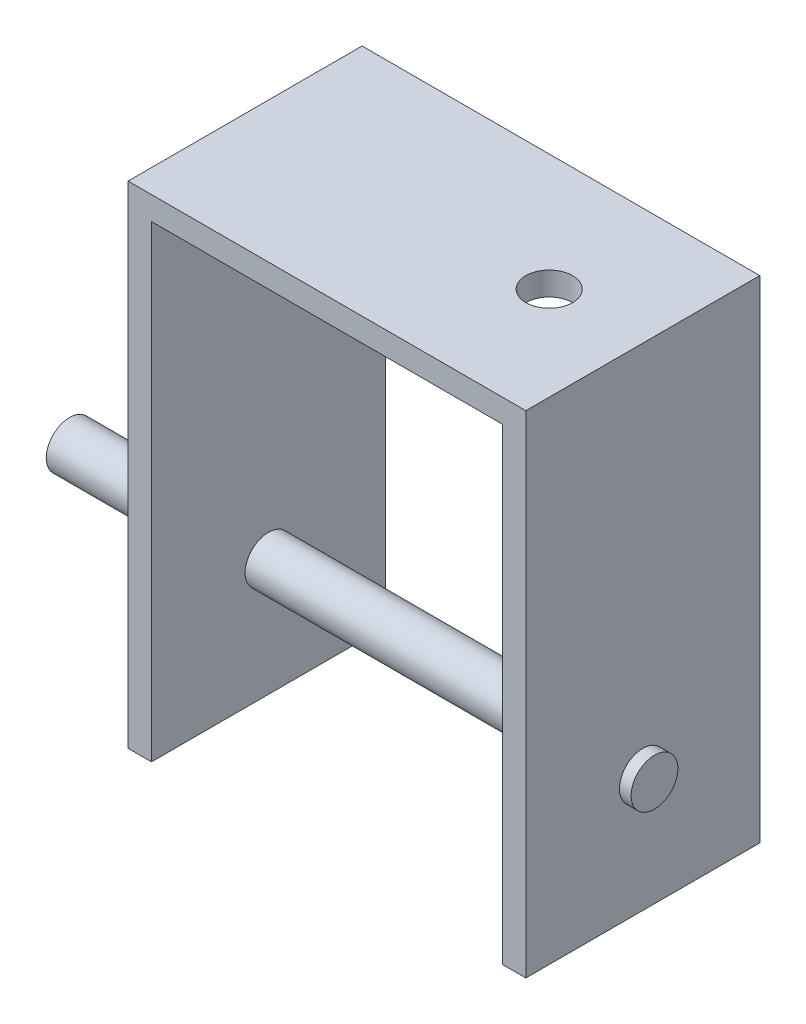
from build123d import *

# Parameters (mm, degrees)
EXTRUDE_1_DEPTH      = 20
SKETCH_3_R           = 2
EXTRUDE_2_DEPTH      = 15
EXTRUDE_2_DEPTH_BACK = 35
SKETCH_4_R           = 2
CUT_EXTRUDE_1_DEPTH  = 2


with BuildPart() as part:
    # 草图1 → 凸台-拉伸1 (new body)
    with BuildSketch(Plane.XY):
        Polygon((-38.9636651, 28.845358616), (-38.9636651, -11.154641384), (-36.9636651, -11.154641384), (-36.9636651, 28.845358616), (-6.9636651, 28.845358616), (-6.9636651, -11.154641384), (-4.9636651, -11.154641384), (-4.9636651, 30.845358616), (-38.9636651, 30.845358616), align=None)
    extrude(amount=EXTRUDE_1_DEPTH)

    # 草图3 → 凸台-拉伸2 (add, two sides)
    with BuildSketch(Plane.ZY.offset(38.9636651)) as extrude_2_sk:
        with Locations((10, -1.154641384)):
            Circle(SKETCH_3_R)
    extrude(amount=EXTRUDE_2_DEPTH)
    extrude(extrude_2_sk.sketch, amount=-EXTRUDE_2_DEPTH_BACK)

    # 草图4 → 切除-拉伸1 (cut)
    with BuildSketch(Plane(origin=(0, 30.845358616, 0), x_dir=(1, 0, 0), z_dir=(0, 1, 0))):
        with Locations((-12.9636651, -10)):
            Circle(SKETCH_4_R)
    extrude(amount=-CUT_EXTRUDE_1_DEPTH, mode=Mode.SUBTRACT)


solid = part.part
